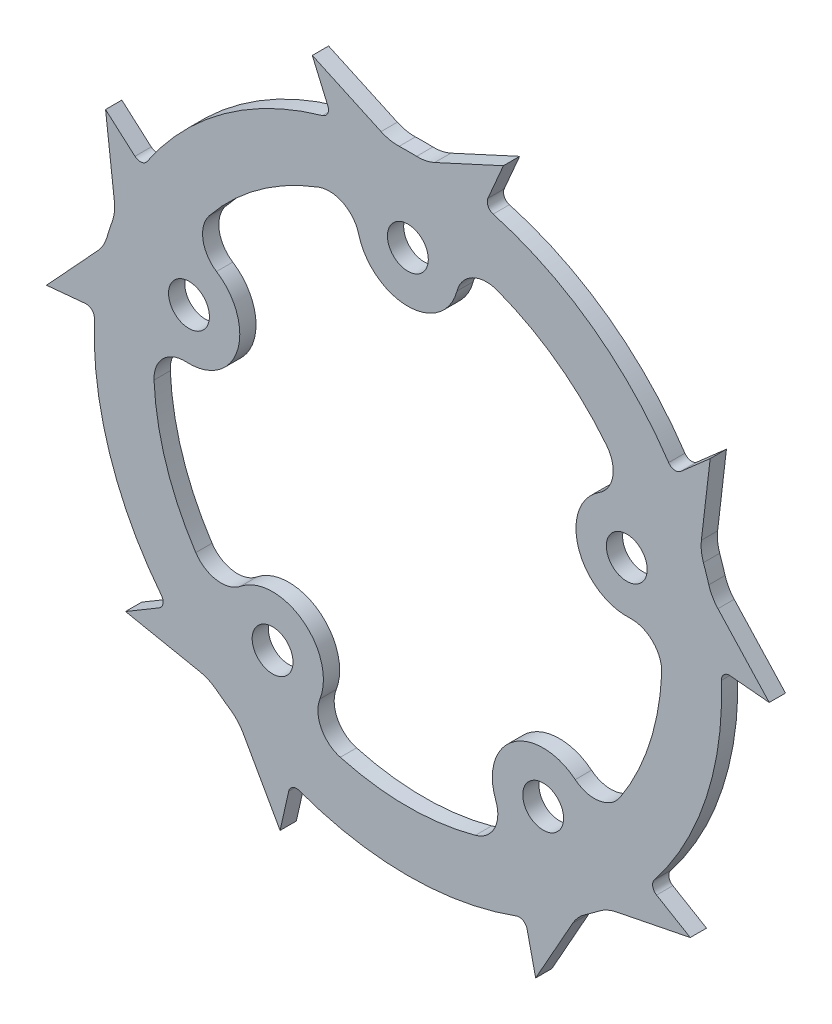
from build123d import *

# Parameters (mm, degrees)
SKETCH1_R                = 39.2
SKETCH1_R_2              = 2.5527
BOSS_EXTRUDE1_DEPTH      = 2.032
BOSS_EXTRUDE5_DEPTH      = 2.032
FILLET2_R                = 1.016
CIRPATTERN2_COUNT        = 5
FILLET2_OF_CIRPATTERN2_R = 1.016


with BuildPart() as part:
    # Sketch1 → Boss-Extrude1 (new body)
    with BuildSketch(Plane.XY):
        Circle(SKETCH1_R)
        with BuildLine():
            ThreePointArc((24.820271985, 19.799409047), (25.601853519, 16.808343049), (23.907855902, 14.222280874))
            ThreePointArc((23.907855902, 14.222280874), (21.312007949, 6.924691149), (27.701508676, 2.546618187))
            ThreePointArc((27.701508676, 2.546618187), (30.592030744, 1.450156756), (31.717822482, -1.429068567))
            ThreePointArc((31.717822482, -1.429068567), (30.196044392, -9.811289571), (26.500242841, -17.487127533))
            ThreePointArc((26.500242841, -17.487127533), (23.89709201, -19.154745969), (20.914126675, -18.342795657))
            ThreePointArc((20.914126675, -18.342795657), (13.171545281, -18.12907679), (10.982214772, -25.558752039))
            ThreePointArc((10.982214772, -25.558752039), (10.832638425, -28.646627104), (8.442221199, -30.607048228))
            ThreePointArc((8.442221199, -30.607048228), (0, -31.75), (-8.442221199, -30.607048228))
            ThreePointArc((-8.442221199, -30.607048228), (-10.832638425, -28.646627104), (-10.982214772, -25.558752039))
            ThreePointArc((-10.982214772, -25.558752039), (-13.171545281, -18.12907679), (-20.914126675, -18.342795657))
            ThreePointArc((-20.914126675, -18.342795657), (-23.89709201, -19.154745969), (-26.500242841, -17.487127533))
            ThreePointArc((-26.500242841, -17.487127533), (-30.196044392, -9.811289571), (-31.717822482, -1.429068567))
            ThreePointArc((-31.717822482, -1.429068567), (-30.592030744, 1.450156756), (-27.701508676, 2.546618187))
            ThreePointArc((-27.701508676, 2.546618187), (-21.312007949, 6.924691149), (-23.907855902, 14.222280874))
            ThreePointArc((-23.907855902, 14.222280874), (-25.601853519, 16.808343049), (-24.820271985, 19.799409047))
            ThreePointArc((-24.820271985, 19.799409047), (-18.66218176, 25.686289571), (-11.160471144, 29.723835281))
            ThreePointArc((-11.160471144, 29.723835281), (-8.07427636, 29.542873268), (-6.138259129, 27.132648635))
            ThreePointArc((-6.138259129, 27.132648635), (0, 22.408771281), (6.138259129, 27.132648635))
            ThreePointArc((6.138259129, 27.132648635), (8.07427636, 29.542873268), (11.160471144, 29.723835281))
            ThreePointArc((11.160471144, 29.723835281), (18.66218176, 25.686289571), (24.820271985, 19.799409047))
        make_face(mode=Mode.SUBTRACT)
        with Locations((27.351216828, 8.886949063)):
            Circle(SKETCH1_R_2, mode=Mode.SUBTRACT)
        with Locations((0, 28.758771281)):
            Circle(SKETCH1_R_2, mode=Mode.SUBTRACT)
        with Locations((16.903981633, -23.266334704)):
            Circle(SKETCH1_R_2, mode=Mode.SUBTRACT)
        with Locations((-27.351216828, 8.886949063)):
            Circle(SKETCH1_R_2, mode=Mode.SUBTRACT)
        with Locations((-16.903981633, -23.266334704)):
            Circle(SKETCH1_R_2, mode=Mode.SUBTRACT)
    extrude(amount=BOSS_EXTRUDE1_DEPTH)

    # Sketch1_5 → Boss-Extrude5 (add)
    with BuildSketch(Plane.XY):
        with BuildLine():
            Line((-11.938, 43.595001502), (-9.536371101, 38.022330626))
            ThreePointArc((-9.536371101, 38.022330626), (-5.343297764, 38.83412377), (-1.086796161, 39.184931723))
            ThreePointArc((-1.086796161, 39.184931723), (-2.244635615, 39.285819975), (-3.349242804, 39.647225009))
            Line((-3.349242804, 39.647225009), (-11.938, 43.595001502))
        make_face()
        with BuildLine():
            ThreePointArc((3.349242804, 39.647225009), (2.244635615, 39.285819975), (1.086796161, 39.184931723))
            ThreePointArc((1.086796161, 39.184931723), (5.343297764, 38.83412377), (9.536371101, 38.022330626))
            Line((9.536371101, 38.022330626), (11.938, 43.595001502))
            Line((11.938, 43.595001502), (3.349242804, 39.647225009))
        make_face()
    boss_extrude5 = extrude(amount=BOSS_EXTRUDE5_DEPTH)

    # Fillet2
    fillet2_edges = [part.edges().sort_by_distance(p)[0] for p in [
        (-9.536371101, 38.022330626, 1.016),
        (9.536371101, 38.022330626, 1.016),
    ]]
    fillet(fillet2_edges, radius=FILLET2_R)

    # CirPattern2: Boss-Extrude5 ×5 about axis
    cirpattern2_axis = Axis((0, 0, 0), (0, 0, 1))
    for i in range(1, CIRPATTERN2_COUNT):
        add(boss_extrude5.rotate(cirpattern2_axis, i * 360 / CIRPATTERN2_COUNT))

    # Fillet2 of CirPattern2
    fillet2_of_cirpattern2_edges = [part.edges().sort_by_distance(p)[0] for p in [
        (-39.108286041, 2.679918452, 1.016),
        (-33.214484572, 20.819174207, 1.016),
        (-14.633878914, -36.366049936, 1.016),
        (-30.064051485, -25.155373348, 1.016),
        (30.064051485, -25.155373348, 1.016),
        (14.633878914, -36.366049936, 1.016),
        (33.214484572, 20.819174207, 1.016),
        (39.108286041, 2.679918452, 1.016),
    ]]
    fillet(fillet2_of_cirpattern2_edges, radius=FILLET2_OF_CIRPATTERN2_R)


solid = part.part
